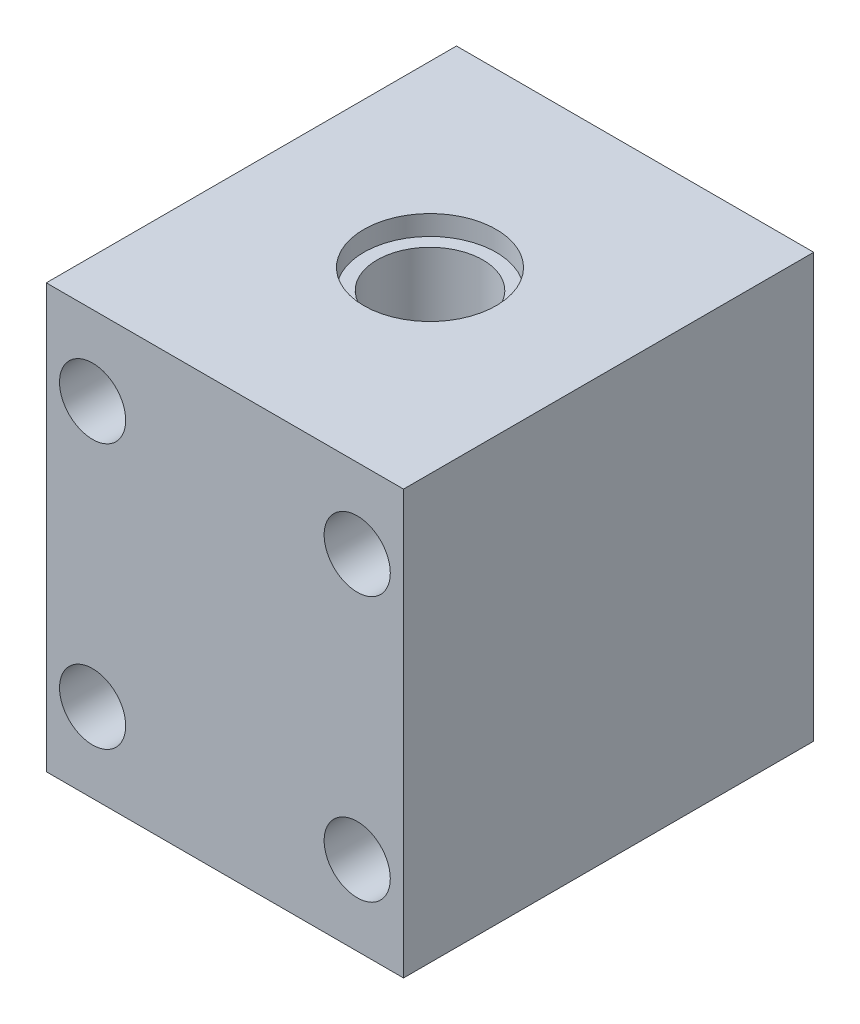
from build123d import *

# Parameters (mm, degrees)
SCHIZZO1_W                   = 27
SCHIZZO1_H                   = 32
ESTRUSIONE_ESTRUSIONE1_DEPTH = 31
SCHIZZO2_R                   = 1.5
TAGLIO_ESTRUSIONE1_DEPTH     = 32
SCHIZZO3_R                   = 4
TAGLIO_ESTRUSIONE2_DEPTH     = 33
SCHIZZO4_R                   = 5
TAGLIO_ESTRUSIONE5_DEPTH     = 1.5
SCHIZZO5_R                   = 5
TAGLIO_ESTRUSIONE6_DEPTH     = 1.5
SCHIZZO6_R                   = 2.5
TAGLIO_ESTRUSIONE7_DEPTH     = 15


with BuildPart() as part:
    # Schizzo1 → Estrusione-Estrusione1 (new body)
    with BuildSketch(Plane.XY):
        Rectangle(SCHIZZO1_W, SCHIZZO1_H)
    extrude(amount=ESTRUSIONE_ESTRUSIONE1_DEPTH)

    # Schizzo2 → Taglio-Estrusione1 (cut, through all)
    with BuildSketch(Plane(origin=(0, 0, 0), x_dir=(-1, 0, 0), z_dir=(0, 0, -1))):
        with Locations((-10, 10)):
            Circle(SCHIZZO2_R)
        with Locations((10, 10)):
            Circle(SCHIZZO2_R)
        with Locations((10, -10)):
            Circle(SCHIZZO2_R)
        with Locations((-10, -10)):
            Circle(SCHIZZO2_R)
    extrude(amount=-TAGLIO_ESTRUSIONE1_DEPTH, mode=Mode.SUBTRACT)

    # Schizzo3 → Taglio-Estrusione2 (cut, through all)
    with BuildSketch(Plane(origin=(0, 16, 0), x_dir=(1, 0, 0), z_dir=(0, 1, 0))):
        with Locations((0, -15.5)):
            Circle(SCHIZZO3_R)
    extrude(amount=-TAGLIO_ESTRUSIONE2_DEPTH, mode=Mode.SUBTRACT)

    # Schizzo4 → Taglio-Estrusione5 (cut)
    with BuildSketch(Plane(origin=(0, 16, 0), x_dir=(1, 0, 0), z_dir=(0, 1, 0))):
        with Locations((0, -15.5)):
            Circle(SCHIZZO4_R)
    extrude(amount=-TAGLIO_ESTRUSIONE5_DEPTH, mode=Mode.SUBTRACT)

    # Schizzo5 → Taglio-Estrusione6 (cut)
    with BuildSketch(Plane.XZ.offset(16)):
        with Locations((0, 15.5)):
            Circle(SCHIZZO5_R)
    extrude(amount=-TAGLIO_ESTRUSIONE6_DEPTH, mode=Mode.SUBTRACT)

    # Schizzo6 → Taglio-Estrusione7 (cut)
    with BuildSketch(Plane.XY.offset(31)):
        with Locations((-10, 10)):
            Circle(SCHIZZO6_R)
        with Locations((10, 10)):
            Circle(SCHIZZO6_R)
        with Locations((10, -10)):
            Circle(SCHIZZO6_R)
        with Locations((-10, -10)):
            Circle(SCHIZZO6_R)
    extrude(amount=-TAGLIO_ESTRUSIONE7_DEPTH, mode=Mode.SUBTRACT)


solid = part.part
